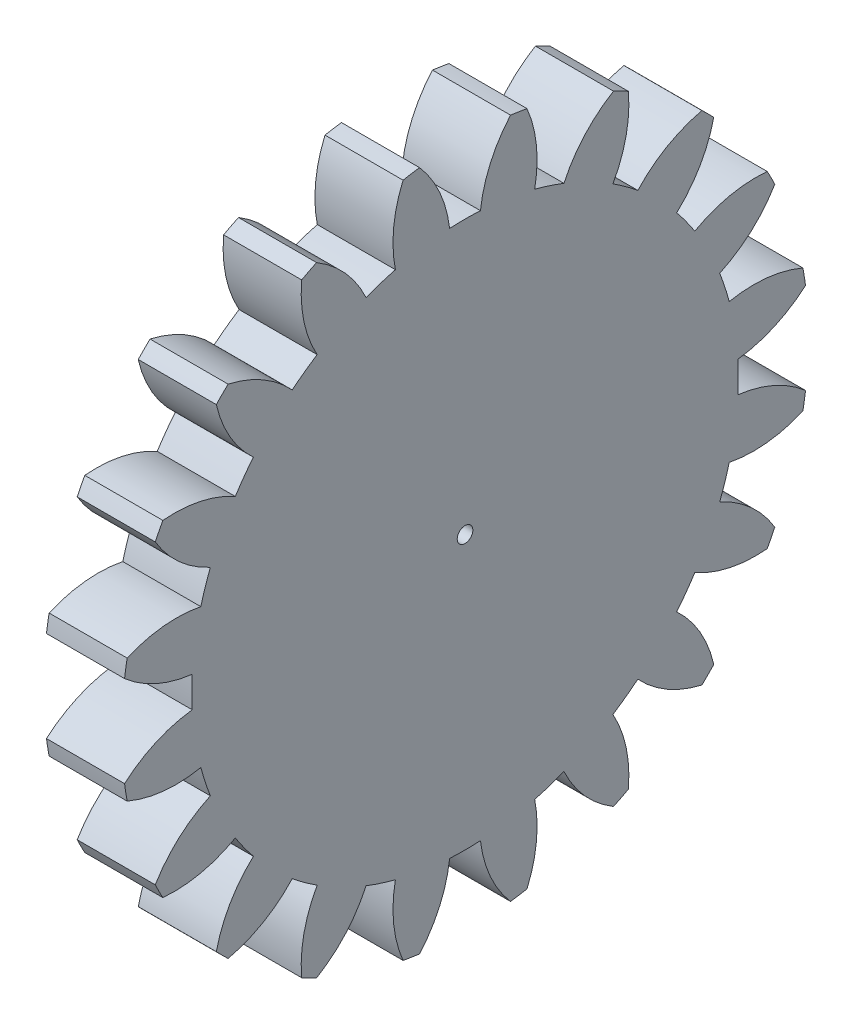
from build123d import *

# Parameters (mm, degrees)
BASPROSKE_W     = 5
BASPROSKE_H     = 22
TOOTHCUT_DEPTH  = 32.511902513
TEETHCUTS_COUNT = 20
TEETHCUTS_ANGLE = 342
BORSKE_R        = 0.5
BORE_DEPTH      = 50.0000508


with BuildPart() as part:
    # BasProSke → Base-Revolve (revolve)
    with BuildSketch(Plane(origin=(0, 0, 0), x_dir=(1, 0, 0), z_dir=(0, 1, 0)), mode=Mode.PRIVATE) as base_revolve_sk:
        with Locations((2.5, 11)):
            Rectangle(BASPROSKE_W, BASPROSKE_H)
    revolve(base_revolve_sk.sketch.rotate(Axis((-10, 0, 0), (1, 0, 0)), 180), axis=Axis((-10, 0, 0), (1, 0, 0)))

    # TooCutSke → ToothCut (cut, through all)
    with BuildSketch(Plane(origin=(0, 0, 0), x_dir=(0, 0, -1), z_dir=(1, 0, 0))):
        with BuildLine():
            ThreePointArc((0.986171591, 17.471189616), (0, 17.499), (-0.986171591, 17.471189616))
            ThreePointArc((-0.986171591, 17.471189616), (-1.626916196, 19.798789858), (-2.932850173, 21.829260982))
            ThreePointArc((-2.932850173, 21.829260982), (0, 22.0254), (2.932850173, 21.829260982))
            ThreePointArc((2.932850173, 21.829260982), (1.626916196, 19.798789858), (0.986171591, 17.471189616))
        make_face()
    toothcut = extrude(amount=TOOTHCUT_DEPTH, mode=Mode.SUBTRACT)

    # TeethCuts: ToothCut ×20 about axis
    teethcuts_axis = Axis((-10, 0, 0), (1, 0, 0))
    for i in range(1, TEETHCUTS_COUNT):
        add(toothcut.rotate(teethcuts_axis, i * TEETHCUTS_ANGLE / (TEETHCUTS_COUNT - 1)), mode=Mode.SUBTRACT)

    # BorSke → Bore (cut, symmetric)
    with BuildSketch(Plane(origin=(0, 0, 0), x_dir=(0, 0, -1), z_dir=(1, 0, 0))):
        with Locations(Location((0, 0, 0), (0, 0, 180))):
            Circle(BORSKE_R)
    extrude(amount=BORE_DEPTH, both=True, mode=Mode.SUBTRACT)


solid = part.part
